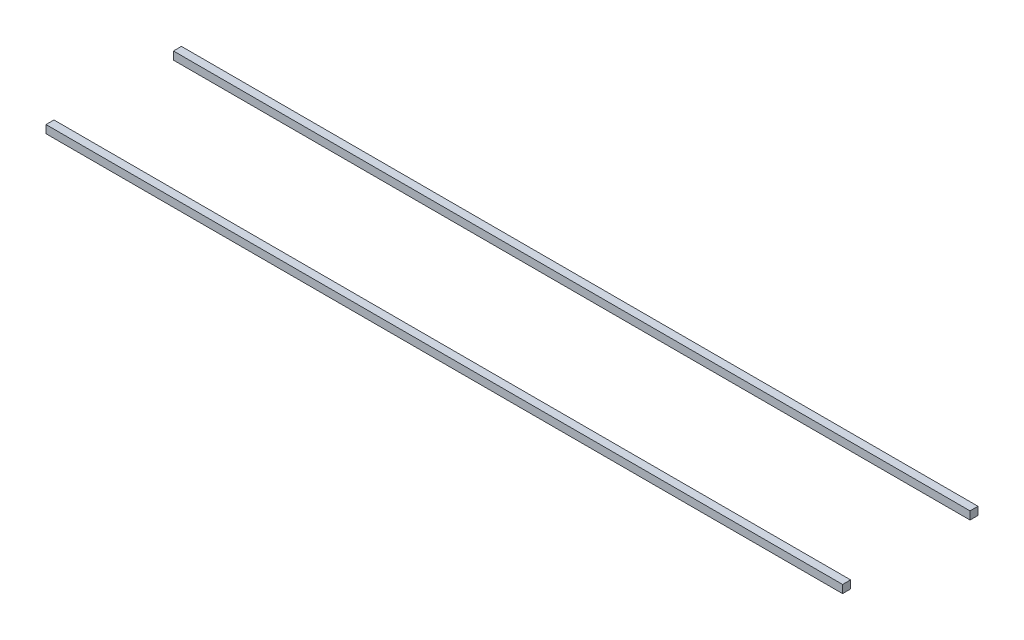
from build123d import *

# Parameters (mm, degrees)
ESBO_O1_W                  = 40
ESBO_O1_H                  = 40
RESSALTO_EXTRUS_O1_DEPTH   = 4000
RESSALTO_EXTRUS_O1_2_DEPTH = 4000


with BuildPart() as part:
    # Esboço1 → Ressalto-extrusão1 (new body)
    with BuildSketch(Plane(origin=(0, 0, 0), x_dir=(0, 0, -1), z_dir=(1, 0, 0))):
        with Locations((320, 0)):
            Rectangle(ESBO_O1_W, ESBO_O1_H)
    extrude(amount=RESSALTO_EXTRUS_O1_DEPTH)


with BuildPart() as body_2:
    # Esboço1 → Ressalto-extrus_o1 2 (new body)
    with BuildSketch(Plane(origin=(0, 0, 0), x_dir=(0, 0, -1), z_dir=(1, 0, 0))):
        with Locations((-320, 0)):
            Rectangle(ESBO_O1_W, ESBO_O1_H)
    extrude(amount=RESSALTO_EXTRUS_O1_2_DEPTH)


solid = Compound([part.part, body_2.part])
